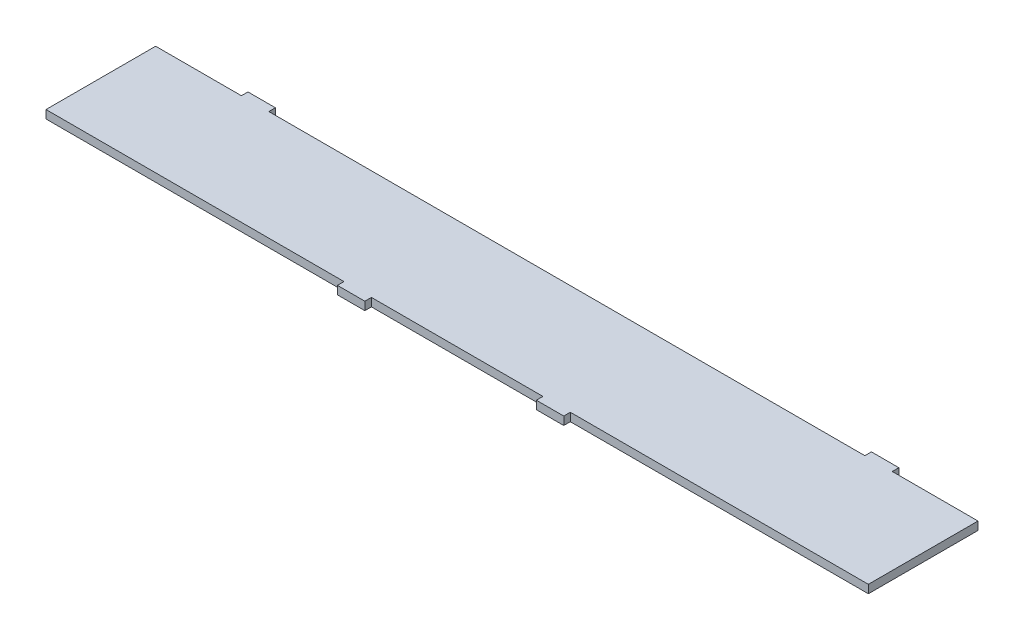
from build123d import *

# Parameters (mm, degrees)
CROQUIS1_W              = 1500
CROQUIS1_H              = 200
SALIENTE_EXTRUIR1_DEPTH = 15
CROQUIS3_W              = 50
CROQUIS3_H              = 12
SALIENTE_EXTRUIR2_DEPTH = 15


with BuildPart() as part:
    # Croquis1 → Saliente-Extruir1 (new body)
    with BuildSketch(Plane(origin=(0, 0, 0), x_dir=(1, 0, 0), z_dir=(0, 1, 0))):
        Rectangle(CROQUIS1_W, CROQUIS1_H)
    extrude(amount=SALIENTE_EXTRUIR1_DEPTH)

    # Croquis3 → Saliente-Extruir2 (add)
    with BuildSketch(Plane(origin=(0, 0, 0), x_dir=(1, 0, 0), z_dir=(0, 1, 0))):
        with Locations((568.59, 106)):
            Rectangle(CROQUIS3_W, CROQUIS3_H)
        with Locations((-568.59, 106)):
            Rectangle(CROQUIS3_W, CROQUIS3_H)
        with Locations((-181.41, -106)):
            Rectangle(CROQUIS3_W, CROQUIS3_H)
        with Locations((181.41, -106)):
            Rectangle(CROQUIS3_W, CROQUIS3_H)
    extrude(amount=SALIENTE_EXTRUIR2_DEPTH)


solid = part.part
